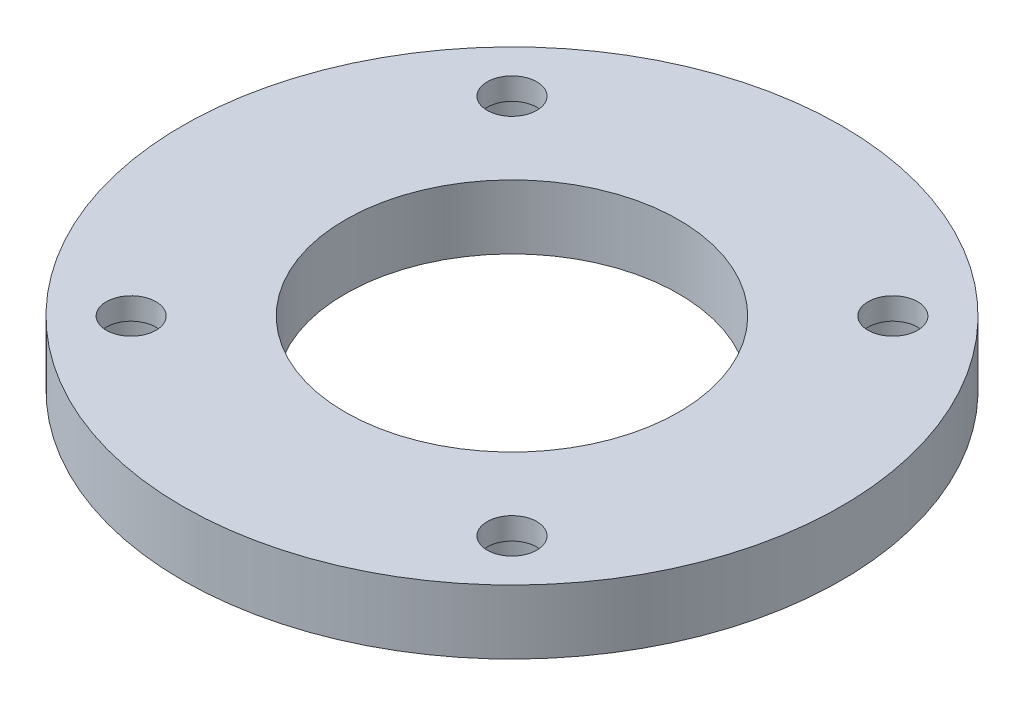
from build123d import *

# Parameters (mm, degrees)
SKETCH1_R                                      = 32.639
SKETCH1_R_2                                    = 16.51
EXTRUDE1_DEPTH                                 = 6.35
CBORE_FOR_8_SOCKET_HEAD_CAP_SCREW1_D           = 4.9149
CBORE_FOR_8_SOCKET_HEAD_CAP_SCREW1_CBORE_D     = 7.9375
CBORE_FOR_8_SOCKET_HEAD_CAP_SCREW1_CBORE_DEPTH = 4.1656


with BuildPart() as part:
    # Sketch1 → Extrude1 (new body)
    with BuildSketch(Plane(origin=(0, 0, 0), x_dir=(1, 0, 0), z_dir=(0, 1, 0))):
        with Locations(Location((0, 0, 0), (0, 0, 270))):  # turned: the seam where the file's is
            Circle(SKETCH1_R)
        with Locations(Location((0, 0, 0), (0, 0, 270))):  # turned: the seam where the file's is
            Circle(SKETCH1_R_2, mode=Mode.SUBTRACT)
    extrude(amount=EXTRUDE1_DEPTH)

    # CBORE for #8 Socket Head Cap Screw1 (through all)
    with Locations(Plane(origin=(-18.858537854, 0, 18.858537854), x_dir=(0, 0, -1), z_dir=(0, -1, 0))):
        with Locations((0, 0), (0, 37.717075708), (37.717075708, 37.717075708), (37.717075708, 0)):
            CounterBoreHole(CBORE_FOR_8_SOCKET_HEAD_CAP_SCREW1_D / 2, CBORE_FOR_8_SOCKET_HEAD_CAP_SCREW1_CBORE_D / 2, CBORE_FOR_8_SOCKET_HEAD_CAP_SCREW1_CBORE_DEPTH)


solid = part.part
